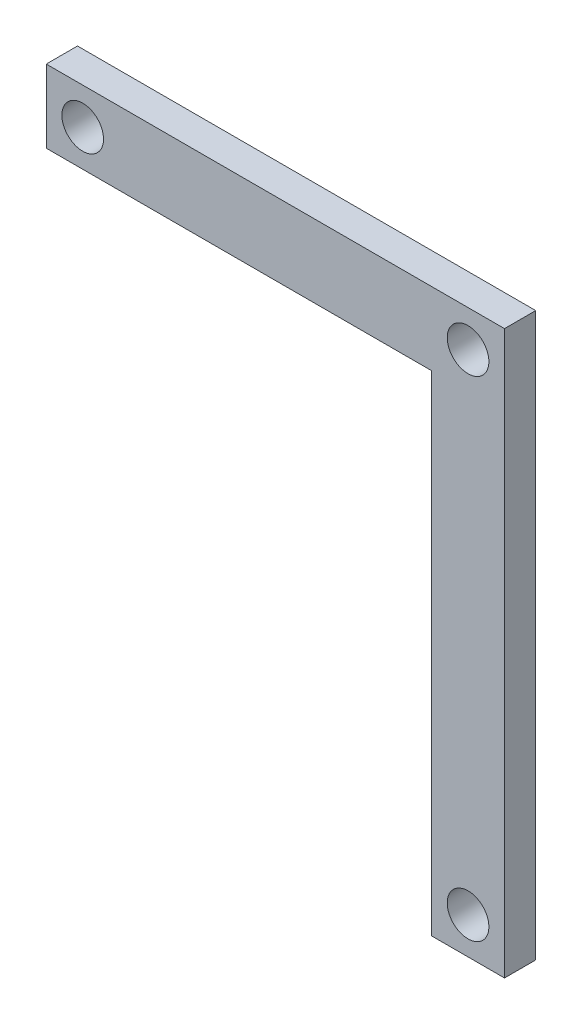
from build123d import *

# Parameters (mm, degrees)
BOSS_EXTRUDE1_DEPTH        = 15
F_20_0MM_DOWEL_HOLE2_D     = 20
F_20_0MM_DOWEL_HOLE2_DEPTH = 22.25
F_20_0MM_DOWEL_HOLE2_TIP   = 6.00860619
F_20_0MM_DOWEL_HOLE1_D     = 20
F_20_0MM_DOWEL_HOLE1_DEPTH = 22.25
F_20_0MM_DOWEL_HOLE1_TIP   = 6.00860619


with BuildPart() as part:
    # Sketch1 → Boss-Extrude1 (new body)
    with BuildSketch(Plane.XY):
        Polygon((0, 0), (-220, 0), (-220, -35), (-35, -35), (-35, -270), (0, -270), align=None)
    extrude(amount=BOSS_EXTRUDE1_DEPTH)

    # Ø20.0mm Dowel Hole2
    with Locations(Plane.XY.offset(15)):
        with Locations((-17.5, -17.5), (-202.5, -17.5), (-17.5, -252.5)):
            Hole(F_20_0MM_DOWEL_HOLE2_D / 2, depth=F_20_0MM_DOWEL_HOLE2_DEPTH)
            with Locations((0, 0, -(F_20_0MM_DOWEL_HOLE2_DEPTH + F_20_0MM_DOWEL_HOLE2_TIP / 2))):  # 118° drill point
                Cone(0, F_20_0MM_DOWEL_HOLE2_D / 2, F_20_0MM_DOWEL_HOLE2_TIP, mode=Mode.SUBTRACT)

    # Ø20.0mm Dowel Hole1
    with Locations(Plane.XY.offset(15)):
        with Locations((-17.5, -17.5), (-202.5, -17.5), (-17.5, -252.5)):
            Hole(F_20_0MM_DOWEL_HOLE1_D / 2, depth=F_20_0MM_DOWEL_HOLE1_DEPTH)
            with Locations((0, 0, -(F_20_0MM_DOWEL_HOLE1_DEPTH + F_20_0MM_DOWEL_HOLE1_TIP / 2))):  # 118° drill point
                Cone(0, F_20_0MM_DOWEL_HOLE1_D / 2, F_20_0MM_DOWEL_HOLE1_TIP, mode=Mode.SUBTRACT)


solid = part.part
